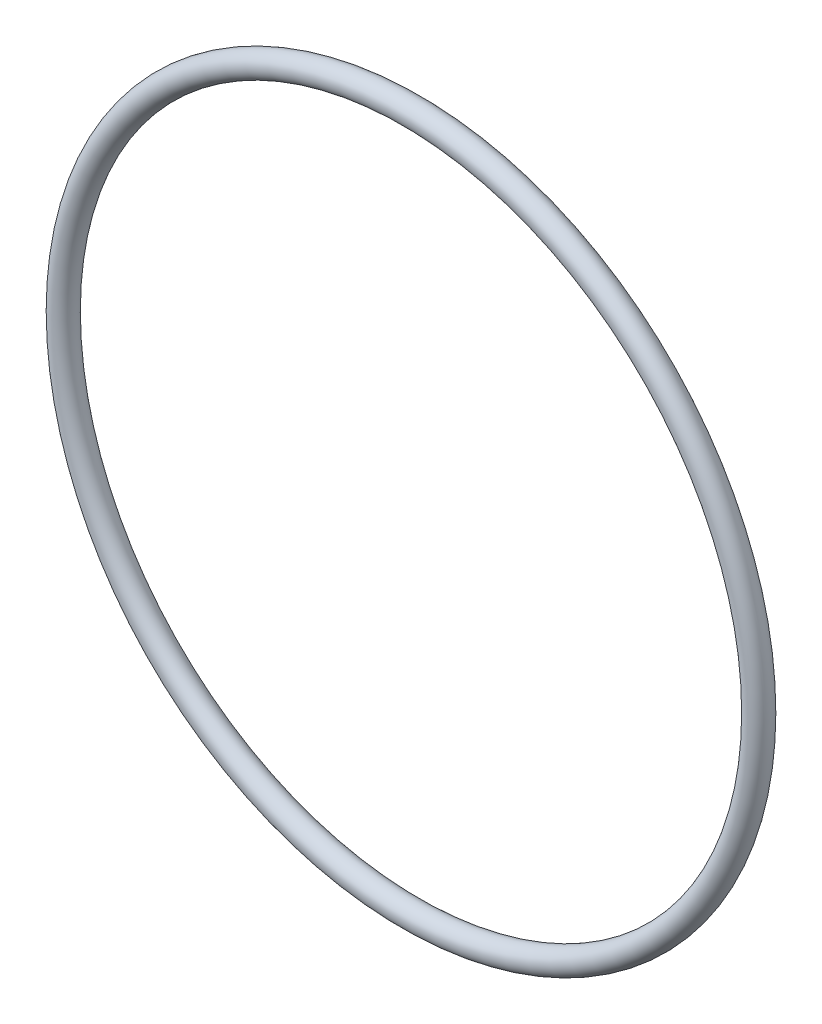
from build123d import *

# Parameters (mm, degrees)
SKETCH1_R = 1.7653


with BuildPart() as part:
    # Sketch1 → Revolve1 (revolve)
    with BuildSketch(Plane(origin=(0, 0, 0), x_dir=(0, -1, 0), z_dir=(1, 0, 0))):
        with Locations((50.7746, 0)):
            Circle(SKETCH1_R)
    revolve(axis=Axis((0, 0, 1.7653), (0, 0, -1)))


solid = part.part
